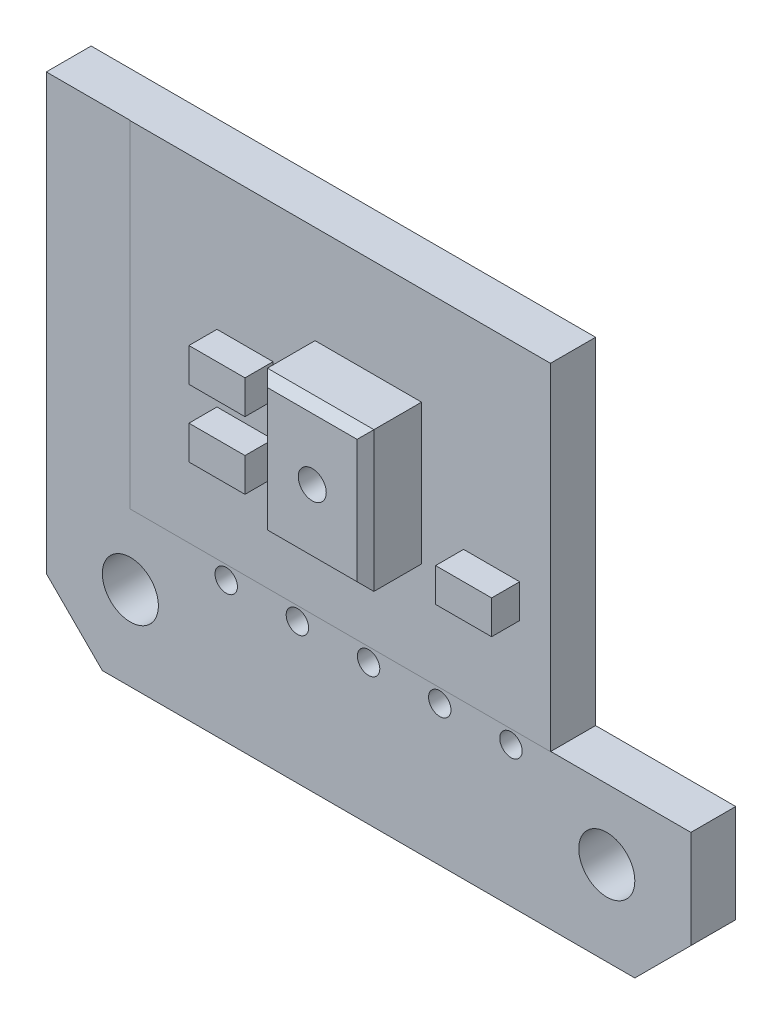
from build123d import *

# Parameters (mm, degrees)
BOSS_EXTRUDE1_DEPTH = 1.6
SKETCH2_W           = 17
SKETCH2_H           = 12
BOSS_EXTRUDE2_DEPTH = 1.61
SKETCH3_R           = 0.4
CUT_EXTRUDE1_DEPTH  = 2.62
BOSS_EXTRUDE4_START = 1.61
SKETCH4_W           = 3.8
SKETCH4_H           = 5
BOSS_EXTRUDE4_DEPTH = 2
BOSS_EXTRUDE5_START = 1.61
SKETCH5_W           = 2
SKETCH5_H           = 1.2
BOSS_EXTRUDE5_DEPTH = 1
CHAMFER1_SIZE       = 0.3
SKETCH8_R           = 1
CUT_EXTRUDE2_DEPTH  = 3.5
SKETCH9_W           = 23
SKETCH9_H           = 5.5
CUT_EXTRUDE3_DEPTH  = 3.5
SKETCH10_W          = 5
SKETCH10_H          = 12
CUT_EXTRUDE4_DEPTH  = 3.5
CUT_EXTRUDE5_START  = 3.61
SKETCH11_R          = 0.5
CUT_EXTRUDE5_DEPTH  = 5


with BuildPart() as part:
    # Sketch1 → Boss-Extrude1 (new body)
    with BuildSketch(Plane.XY):
        Polygon((-11.5, 9.5), (-9.5, 11.5), (9.5, 11.5), (11.5, 9.5), (11.5, -9.5), (9.5, -11.5), (-9.5, -11.5), (-11.5, -9.5), align=None)
    extrude(amount=BOSS_EXTRUDE1_DEPTH)

    # Sketch2 → Boss-Extrude2 (add)
    with BuildSketch(Plane.XY):
        Rectangle(SKETCH2_W, SKETCH2_H)
    extrude(amount=BOSS_EXTRUDE2_DEPTH)

    # Sketch3 → Cut-Extrude1 (cut)
    with BuildSketch(Plane.XY):
        with Locations((-5.08, -6.5)):
            Circle(SKETCH3_R)
        with Locations((-2.54, -6.5)):
            Circle(SKETCH3_R)
        with Locations((0, -6.5)):
            Circle(SKETCH3_R)
        with Locations((2.54, -6.5)):
            Circle(SKETCH3_R)
        with Locations((5.08, -6.5)):
            Circle(SKETCH3_R)
    extrude(amount=CUT_EXTRUDE1_DEPTH, mode=Mode.SUBTRACT)

    # Sketch4 → Boss-Extrude4 (add)
    with BuildSketch(Plane.XY.offset(BOSS_EXTRUDE4_START)):
        Rectangle(SKETCH4_W, SKETCH4_H)
    extrude(amount=BOSS_EXTRUDE4_DEPTH)

    # Sketch5 → Boss-Extrude5 (add)
    with BuildSketch(Plane.XY.offset(BOSS_EXTRUDE5_START)):
        with Locations((-4.4, -1.9)):
            Rectangle(SKETCH5_W, SKETCH5_H)
        with Locations((-4.4, 0.5)):
            Rectangle(SKETCH5_W, SKETCH5_H)
        with Locations((4.4, -1.9)):
            Rectangle(SKETCH5_W, SKETCH5_H)
    extrude(amount=BOSS_EXTRUDE5_DEPTH)

    # Chamfer1
    chamfer1_edges = [part.edges().sort_by_distance(p)[0] for p in [
        (1.9, 0, 3.61),
        (0, 2.5, 3.61),
        (-1.9, 0, 3.61),
        (0, -2.5, 3.61),
    ]]
    chamfer(chamfer1_edges, length=CHAMFER1_SIZE)

    # Sketch8 → Cut-Extrude2 (cut, symmetric)
    with BuildSketch(Plane.XY):
        with Locations((8.5, -8.5)):
            Circle(SKETCH8_R)
        with Locations((-8.5, -8.5)):
            Circle(SKETCH8_R)
        with Locations((8.5, 8.5)):
            Circle(SKETCH8_R)
        with Locations((-8.5, 8.5)):
            Circle(SKETCH8_R)
    extrude(amount=CUT_EXTRUDE2_DEPTH, both=True, mode=Mode.SUBTRACT)

    # Sketch9 → Cut-Extrude3 (cut, symmetric)
    with BuildSketch(Plane.XY):
        with Locations((0, 8.75)):
            Rectangle(SKETCH9_W, SKETCH9_H)
    extrude(amount=CUT_EXTRUDE3_DEPTH, both=True, mode=Mode.SUBTRACT)

    # Sketch10 → Cut-Extrude4 (cut, symmetric)
    with BuildSketch(Plane.XY):
        with Locations((9, 0)):
            Rectangle(SKETCH10_W, SKETCH10_H)
    extrude(amount=CUT_EXTRUDE4_DEPTH, both=True, mode=Mode.SUBTRACT)

    # Sketch11 → Cut-Extrude5 (cut)
    with BuildSketch(Plane.XY.offset(CUT_EXTRUDE5_START)):
        Circle(SKETCH11_R)
    extrude(amount=-CUT_EXTRUDE5_DEPTH, mode=Mode.SUBTRACT)


solid = part.part
